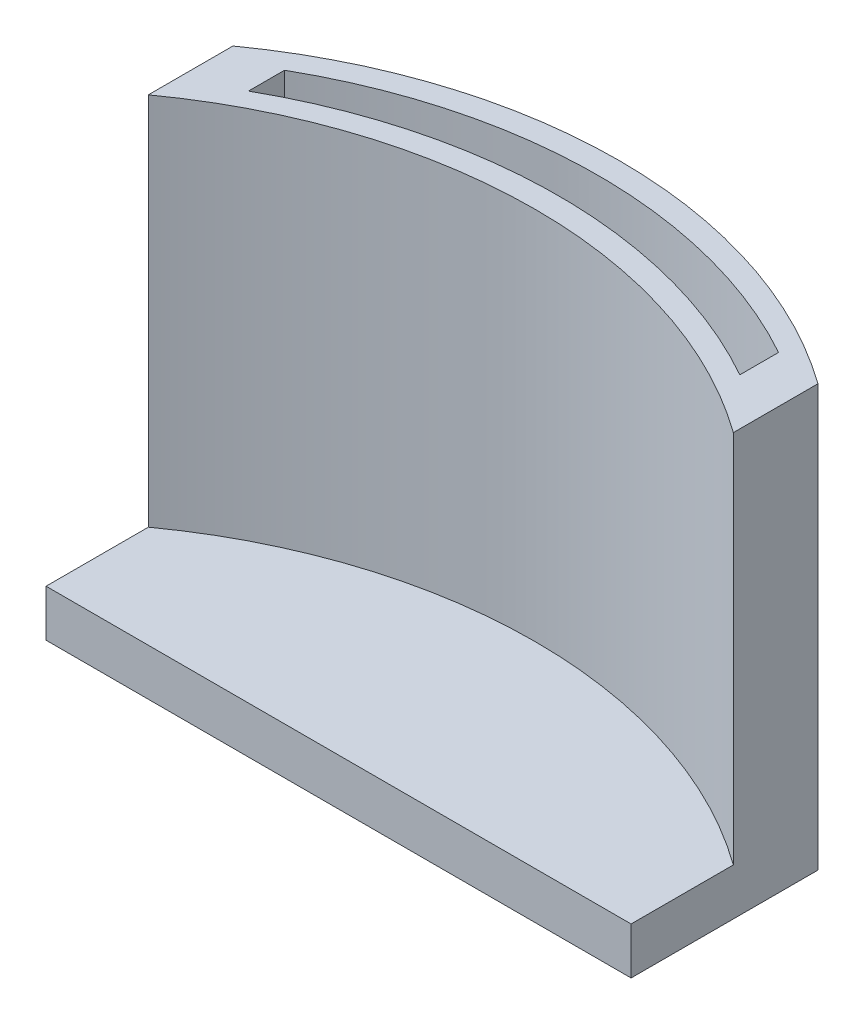
from build123d import *

# Parameters (mm, degrees)
BOSS_EXTRUDE1_DEPTH = 2.54
BOSS_EXTRUDE4_DEPTH = 20.32
SKETCH3_W           = 31.75
SKETCH3_H           = 16.51
CUT_EXTRUDE1_DEPTH  = 2.54


with BuildPart() as part:
    # Sketch1 → Boss-Extrude1 (new body)
    with BuildSketch(Plane(origin=(0, 0, 0), x_dir=(1, 0, 0), z_dir=(0, 1, 0))):
        with BuildLine():
            Line((0, 0), (31.75, 0))
            Line((31.75, 0), (31.75, 26.649569904))
            ThreePointArc((31.75, 26.649569904), (15.875, 31.75), (0, 26.649569904))
            Line((0, 26.649569904), (0, 0))
        make_face()
    extrude(amount=BOSS_EXTRUDE1_DEPTH)

    # Sketch2 → Boss-Extrude4 (add)
    with BuildSketch(Plane(origin=(0, 2.54, 0), x_dir=(1, 0, 0), z_dir=(0, 1, 0))):
        with BuildLine():
            Line((31.75, 22.059647753), (31.75, 26.649569904))
            ThreePointArc((31.75, 26.649569904), (15.875, 31.75), (0, 26.649569904))
            Line((0, 26.649569904), (0, 22.059647753))
            ThreePointArc((0, 22.059647753), (15.875, 27.178), (31.75, 22.059647753))
        make_face()
        with BuildLine():
            Line((2.54, 26.911706478), (2.54, 24.951669261))
            ThreePointArc((2.54, 24.951669261), (15.875, 28.448), (29.21, 24.951669261))
            Line((29.21, 24.951669261), (29.21, 27.054735))
            ThreePointArc((29.21, 27.054735), (15.856249221, 30.479609179), (2.54, 26.911706478))
        make_face(mode=Mode.SUBTRACT)
    extrude(amount=BOSS_EXTRUDE4_DEPTH)

    # Sketch3 → Cut-Extrude1 (cut)
    with BuildSketch(Plane(origin=(0, 2.54, 0), x_dir=(1, 0, 0), z_dir=(0, 1, 0))):
        with Locations((15.875, 8.255)):
            Rectangle(SKETCH3_W, SKETCH3_H)
    extrude(amount=-CUT_EXTRUDE1_DEPTH, mode=Mode.SUBTRACT)


solid = part.part
